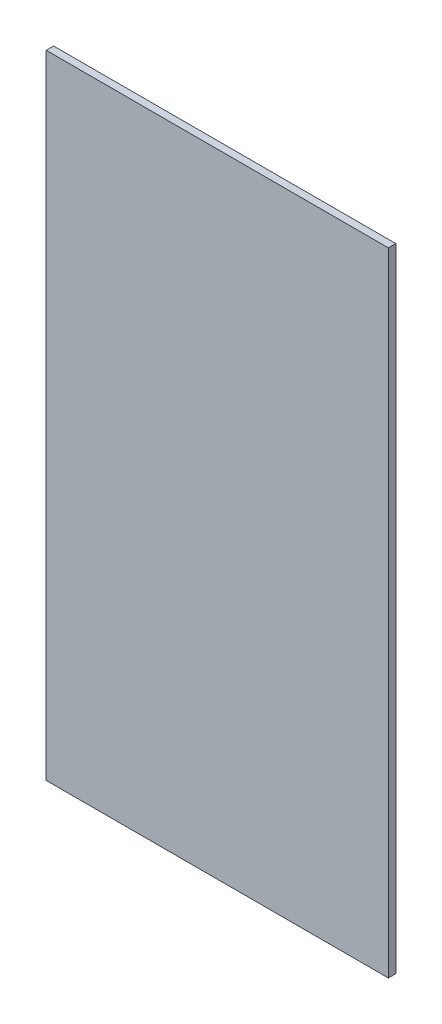
from build123d import *

# Parameters (mm, degrees)
SKETCH1_W           = 230
SKETCH1_H           = 425
BOSS_EXTRUDE1_DEPTH = 5


with BuildPart() as part:
    # Sketch1 → Boss-Extrude1 (new body)
    with BuildSketch(Plane.XY):
        with Locations((0, 5)):
            Rectangle(SKETCH1_W, SKETCH1_H)
    extrude(amount=BOSS_EXTRUDE1_DEPTH)


solid = part.part
